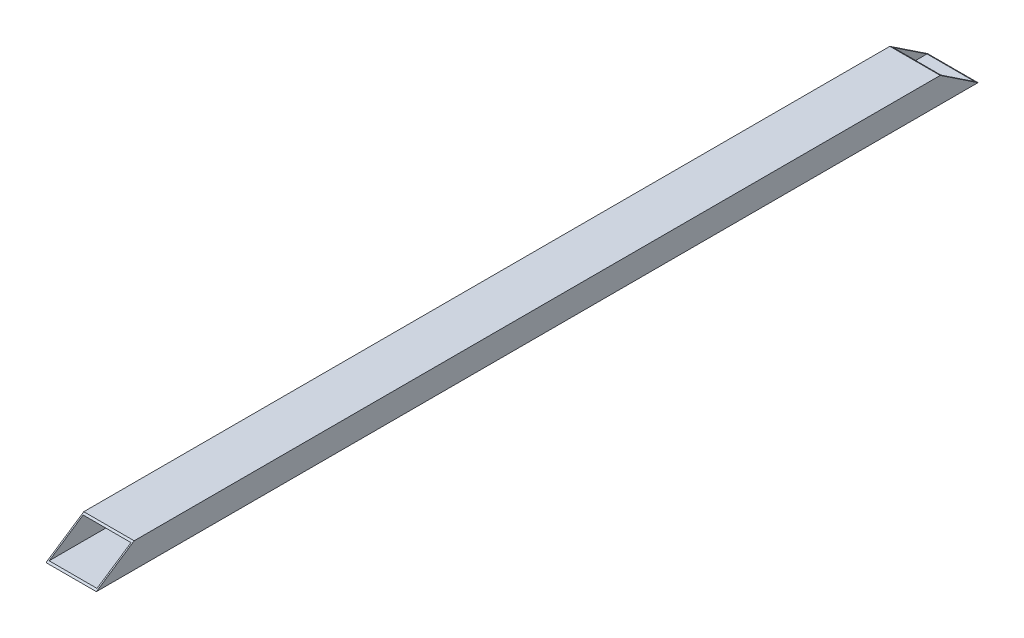
from build123d import *

# Parameters (mm, degrees)
BOSS_EXTRUDE1_DEPTH = 700
SKETCH4_W           = 38
SKETCH4_H           = 18
CUT_EXTRUDE2_DEPTH  = 701
CUT_EXTRUDE1_DEPTH  = 41


with BuildPart() as part:
    # Sketch1 → Boss-Extrude1 (new body)
    with BuildSketch(Plane.XY):
        Polygon((20, -8), (0, -8), (-20, -8), (-20, 12), (20, 12), align=None)
    extrude(amount=BOSS_EXTRUDE1_DEPTH)

    # Sketch4 → Cut-Extrude2 (cut, through all)
    with BuildSketch(Plane.XY.offset(700)):
        with Locations((0, 2)):
            Rectangle(SKETCH4_W, SKETCH4_H)
    extrude(amount=-CUT_EXTRUDE2_DEPTH, mode=Mode.SUBTRACT)

    # Sketch3 → Cut-Extrude1 (cut, through all)
    with BuildSketch(Plane.ZY.offset(20)):
        Polygon((0, 12), (30, 12), (0, -8), align=None)
        Polygon((670, 12), (700, 12), (700, -8), align=None)
    extrude(amount=-CUT_EXTRUDE1_DEPTH, mode=Mode.SUBTRACT)


solid = part.part
